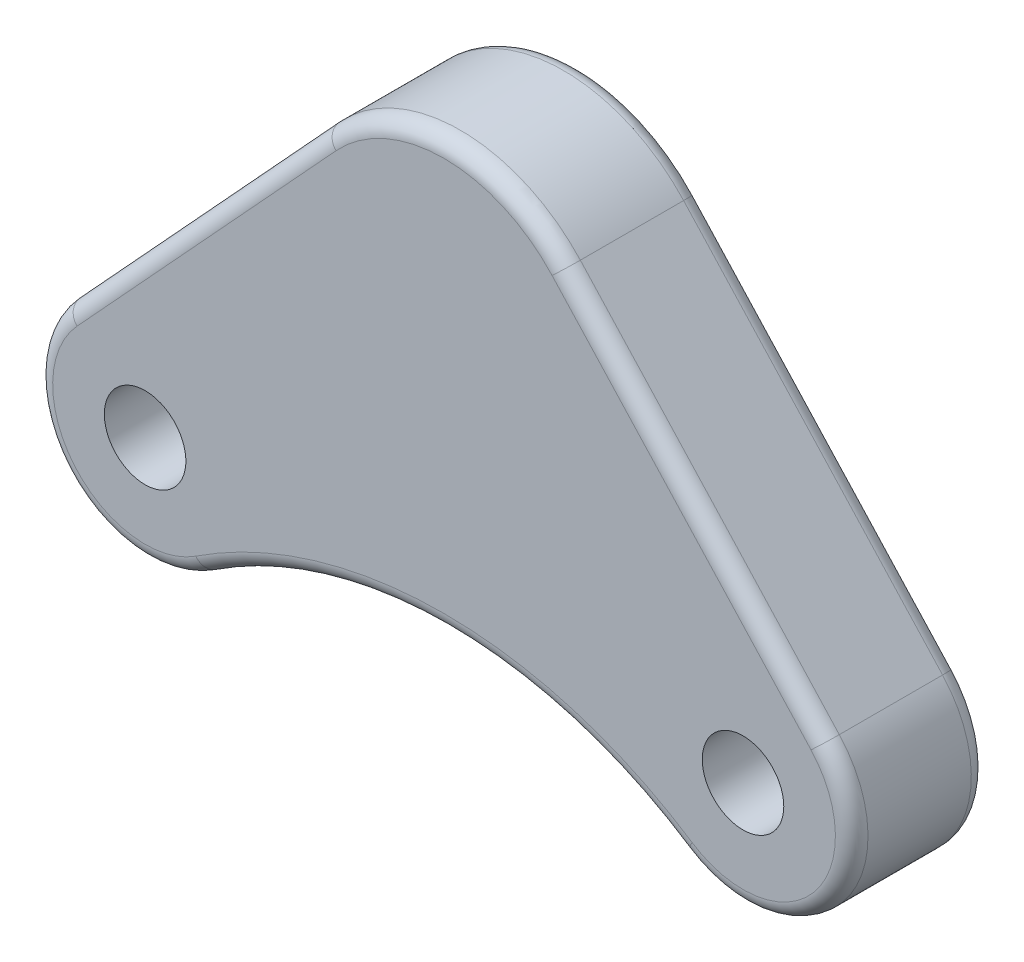
from build123d import *

# Parameters (mm, degrees)
SKETCH1_R           = 7.5
BOSS_EXTRUDE2_DEPTH = 25
FILLET2_R           = 3


with BuildPart() as part:
    # Sketch1 → Boss-Extrude2 (new body)
    with BuildSketch(Plane.XY):
        with BuildLine():
            Line((22.075429532, 20.314413872), (69.716953021, -31.457057418))
            ThreePointArc((69.716953021, -31.457057418), (70.236883802, -57.955206367), (44, -61.703293088))
            ThreePointArc((44, -61.703293088), (0, -48.516465442), (-44, -61.703293088))
            ThreePointArc((-44, -61.703293088), (-70.236883802, -57.955206367), (-69.716953021, -31.457057418))
            Line((-69.716953021, -31.457057418), (-22.075429532, 20.314413872))
            ThreePointArc((-22.075429532, 20.314413872), (0, 30), (22.075429532, 20.314413872))
        make_face()
        with Locations((55, -45)):
            Circle(SKETCH1_R, mode=Mode.SUBTRACT)
        with Locations((-55, -45)):
            Circle(SKETCH1_R, mode=Mode.SUBTRACT)
    extrude(amount=BOSS_EXTRUDE2_DEPTH)

    # Fillet2
    fillet2_edges = [part.edges().sort_by_distance(p)[0] for p in [
        (-70.236883802, -57.955206367, 25),
        (0, -48.516465442, 25),
        (70.236883802, -57.955206367, 25),
        (45.896191277, -5.571321773, 25),
        (0, 30, 25),
        (45.896191277, -5.571321773, 0),
        (70.236883802, -57.955206367, 0),
        (0, -48.516465442, 0),
        (-70.236883802, -57.955206367, 0),
        (-45.896191277, -5.571321773, 0),
        (0, 30, 0),
        (-45.896191277, -5.571321773, 25),
    ]]
    fillet(fillet2_edges, radius=FILLET2_R)


solid = part.part
